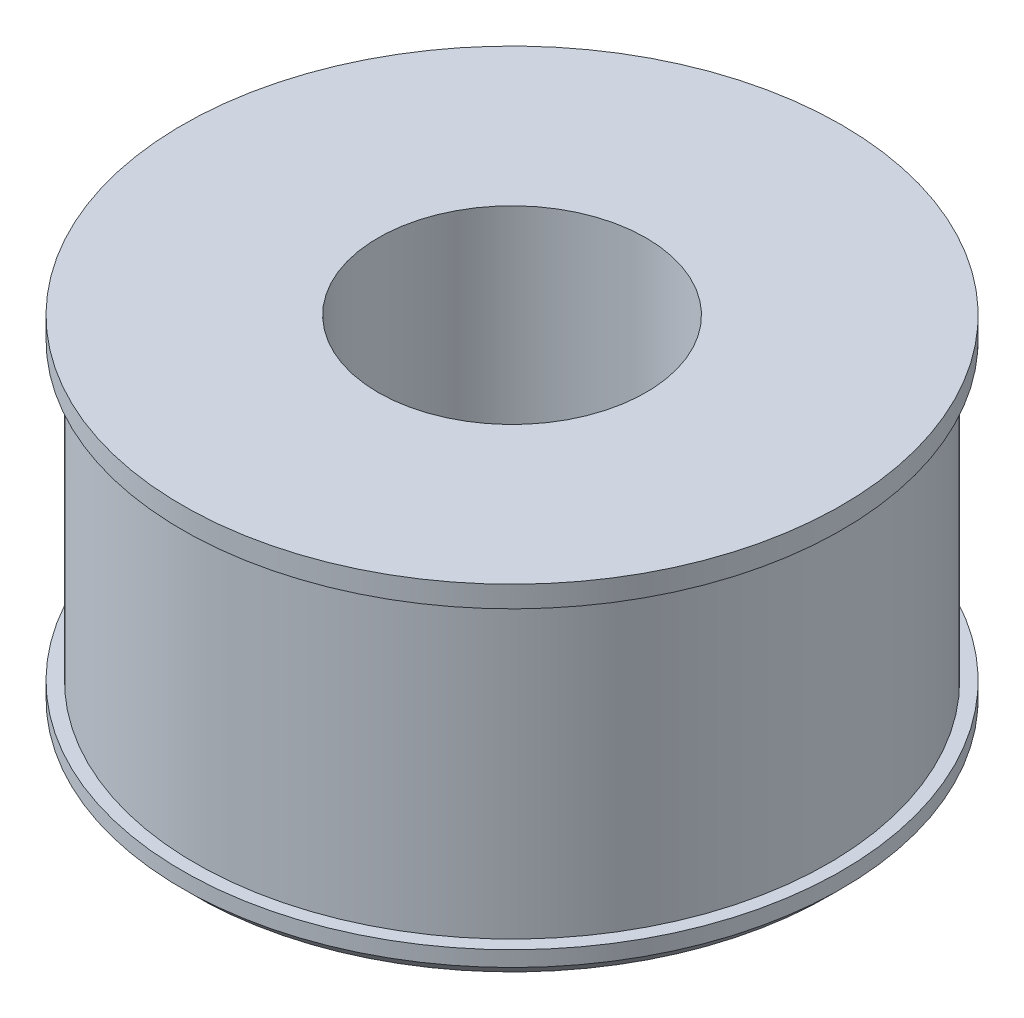
from build123d import *


with BuildPart() as part:
    # Croquis1 → Revolución1 (revolve)
    with BuildSketch(Plane(origin=(0, 0, 0), x_dir=(0, 0, -1), z_dir=(1, 0, 0))):
        Polygon((54.267285515, 67.95416726), (54.267285515, -66.513442866), (128.224471084, -66.513442866), (128.224471084, -60.270303824), (128.224471084, 59.309820895), (133.507127196, 59.309820895), (133.507127196, 67.95416726), align=None)
        Polygon((128.224471084, -60.270303824), (128.224471084, -66.513442866), (128.224471084, -71.796098978), (133.507127196, -66.513442866), (133.507127196, -60.270303824), align=None)
    revolve(axis=Axis((0, -66.513442866, 0), (0, 1, 0)))


solid = part.part
